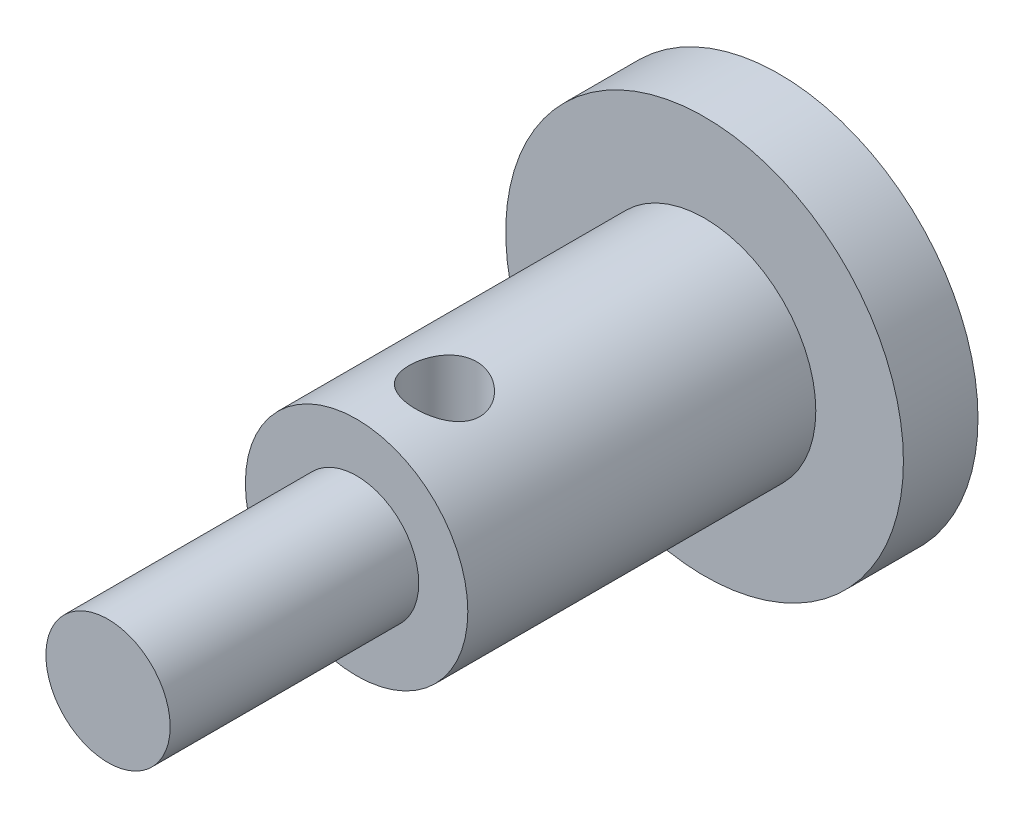
from build123d import *

# Parameters (mm, degrees)
SKETCH1_R           = 8
BOSS_EXTRUDE1_DEPTH = 3
SKETCH2_R           = 4.475
BOSS_EXTRUDE2_DEPTH = 14
SKETCH3_R           = 2.5
BOSS_EXTRUDE3_DEPTH = 10
SKETCH4_R           = 1.425
CUT_EXTRUDE1_DEPTH  = 7.5


with BuildPart() as part:
    # Sketch1 → Boss-Extrude1 (new body)
    with BuildSketch(Plane.XY):
        Circle(SKETCH1_R)
    extrude(amount=BOSS_EXTRUDE1_DEPTH)

    # Sketch2 → Boss-Extrude2 (add)
    with BuildSketch(Plane.XY.offset(3)):
        Circle(SKETCH2_R)
    extrude(amount=BOSS_EXTRUDE2_DEPTH)

    # Sketch3 → Boss-Extrude3 (add)
    with BuildSketch(Plane.XY.offset(17)):
        Circle(SKETCH3_R)
    extrude(amount=BOSS_EXTRUDE3_DEPTH)

    # Sketch4 → Cut-Extrude1 (cut, symmetric)
    with BuildSketch(Plane(origin=(0, 0, 0), x_dir=(1, 0, 0), z_dir=(0, 1, 0))):
        with Locations((0.525, -13.990152787)):
            Circle(SKETCH4_R)
    extrude(amount=CUT_EXTRUDE1_DEPTH, both=True, mode=Mode.SUBTRACT)


solid = part.part
